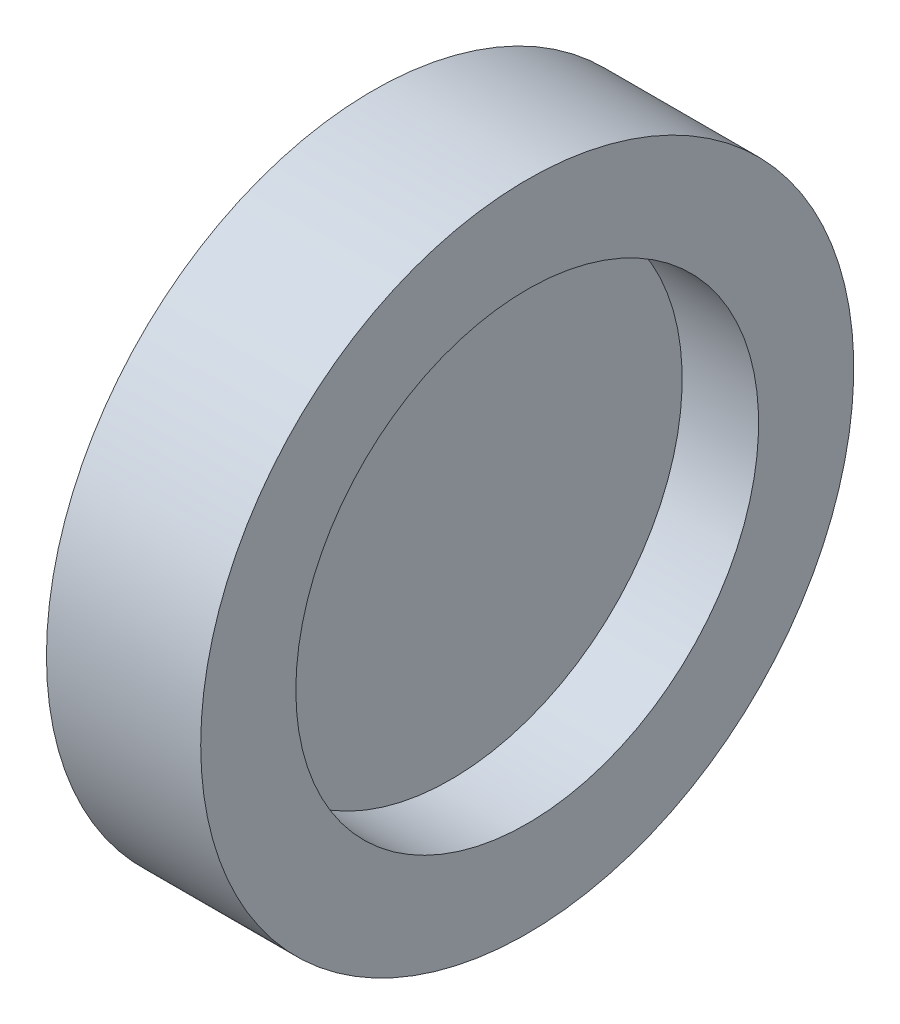
from build123d import *

# Parameters (mm, degrees)
SKETCH_1_W = 0.054
SKETCH_1_H = 9
SKETCH_4_W = 6
SKETCH_4_H = 3.7


with BuildPart() as part:
    # 草图1 → 旋转2 (revolve)
    with BuildSketch(Plane.XY, mode=Mode.PRIVATE) as revolve_2_sk:
        with Locations((0, 4.5)):
            Rectangle(SKETCH_1_W, SKETCH_1_H)
    revolve(revolve_2_sk.sketch.rotate(Axis((-0.027, 0, 0), (1, 0, 0)), 90), axis=Axis((-0.027, 0, 0), (1, 0, 0)))  # turned: the seam where the file's is

    # 草图4 → 旋转3 (revolve)
    with BuildSketch(Plane.XY, mode=Mode.PRIVATE) as revolve_3_sk:
        with Locations((0, 10.85)):
            Rectangle(SKETCH_4_W, SKETCH_4_H)
    revolve(revolve_3_sk.sketch.rotate(Axis((-1.614212419, 0, 0), (1, 0, 0)), 90), axis=Axis((-1.614212419, 0, 0), (1, 0, 0)))  # turned: the seam where the file's is


solid = part.part
